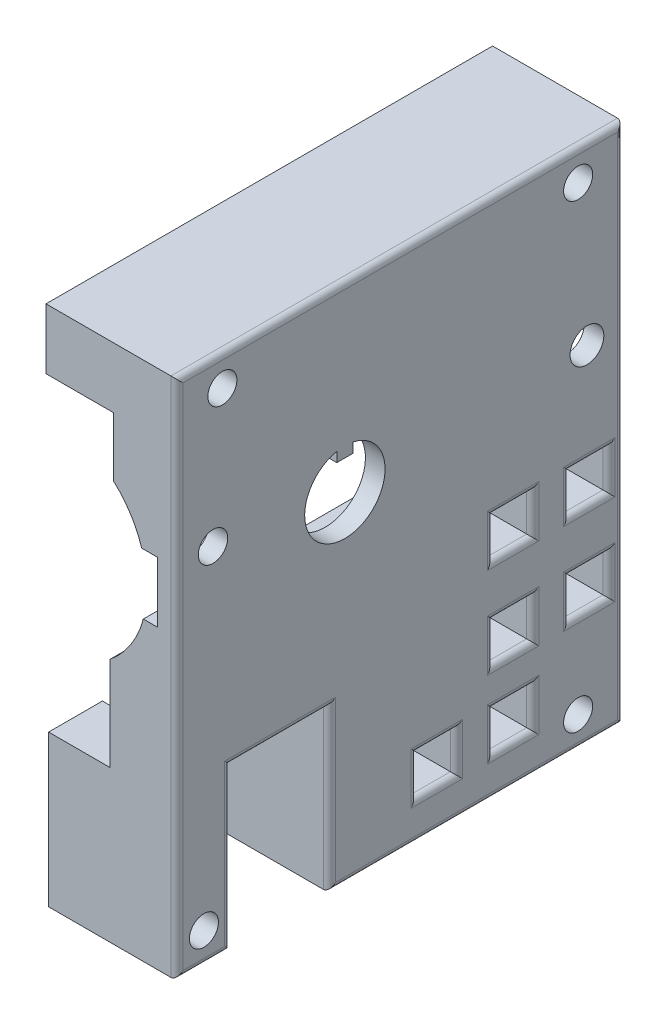
from build123d import *

# Parameters (mm, degrees)
PROFILEEXTRUDE_DEPTH = 73.76
HOSEWINDOW_W         = 16.29
HOSEWINDOW_H         = 26.5
HOSEWINDOWCUT_DEPTH  = 22.63
CAGESCREWS_R         = 2.4
CAGESCREWSCUT_DEPTH  = 22.63
AXLEHOLECUT_DEPTH    = 22.63
SETSCREWS_R          = 2.426338021
SETSCREWS_R_2        = 2.788762315
SETSCREWSCUT_DEPTH   = 22.63
SKETCH1_W            = 6.5
SKETCH1_H            = 6.5
CUT_EXTRUDE1_DEPTH   = 22.63
FILLET1_R            = 1


with BuildPart() as part:
    # Profile → ProfileExtrude (new body)
    with BuildSketch(Plane.XY):
        with BuildLine():
            Line((-6.01073477, -58.62791746), (-6.01073477, -33.62791746))
            Line((-6.01073477, -33.62791746), (4.13926523, -33.62791746))
            Line((4.13926523, -33.62791746), (4.13926523, -18.13791746))
            ThreePointArc((4.13926523, -18.13791746), (7.563334043, -14.326029686), (9.63126523, -9.63791746))
            Line((9.63126523, -9.63791746), (11.94926523, -9.63791746))
            Line((11.94926523, -9.63791746), (11.94926523, 0.36208254))
            Line((11.94926523, 0.36208254), (9.35926523, 0.36208254))
            ThreePointArc((9.35926523, 0.36208254), (7.525939238, 4.313848402), (4.70926523, 7.63708254))
            Line((4.70926523, 7.63708254), (4.70926523, 17.41208254))
            Line((4.70926523, 17.41208254), (-6.44073477, 17.41208254))
            Line((-6.44073477, 17.41208254), (-6.44073477, 27.41208254))
            Line((-6.44073477, 27.41208254), (15.18926523, 27.41208254))
            Line((15.18926523, 27.41208254), (15.18926523, -58.62791746))
            Line((15.18926523, -58.62791746), (-6.01073477, -58.62791746))
        make_face()
    extrude(amount=PROFILEEXTRUDE_DEPTH)

    # HoseWindow → HoseWindowCut (cut, through all)
    with BuildSketch(Plane(origin=(15.18926523, 0, 0), x_dir=(0, 0, -1), z_dir=(1, 0, 0))):
        with Locations((-56.725, -45.37791746)):
            Rectangle(HOSEWINDOW_W, HOSEWINDOW_H)
    extrude(amount=-HOSEWINDOWCUT_DEPTH, mode=Mode.SUBTRACT)

    # CageScrews → CageScrewsCut (cut, through all)
    with BuildSketch(Plane(origin=(15.18926523, 0, 0), x_dir=(0, 0, -1), z_dir=(1, 0, 0))):
        with Locations((-66.26, 22.41208254)):
            Circle(CAGESCREWS_R)
        with Locations((-7.5, 22.41208254)):
            Circle(CAGESCREWS_R)
        with Locations((-7.5, -53.62791746)):
            Circle(CAGESCREWS_R)
        with Locations((-69.31, -53.62791746)):
            Circle(CAGESCREWS_R)
    extrude(amount=-CAGESCREWSCUT_DEPTH, mode=Mode.SUBTRACT)

    # AxleHole → AxleHoleCut (cut, through all)
    with BuildSketch(Plane(origin=(15.18926523, 0, 0), x_dir=(0, 0, -1), z_dir=(1, 0, 0))):
        with BuildLine():
            Line((-44.699, 2.307293484), (-47.361, 2.307293484))
            Line((-47.361, 2.307293484), (-47.361, 3.926293484))
            ThreePointArc((-47.361, 3.926293484), (-46.03, -9.21691746), (-44.699, 3.926293484))
            Line((-44.699, 3.926293484), (-44.699, 2.307293484))
        make_face()
    extrude(amount=-AXLEHOLECUT_DEPTH, mode=Mode.SUBTRACT)

    # SetScrews → SetScrewsCut (cut, through all)
    with BuildSketch(Plane(origin=(15.18926523, 0, 0), x_dir=(0, 0, -1), z_dir=(1, 0, 0))):
        with Locations((-67.80722939, 0.544946624)):
            Circle(SETSCREWS_R)
        with Locations((-6.04299884, -1.55824191)):
            Circle(SETSCREWS_R_2)
    extrude(amount=-SETSCREWSCUT_DEPTH, mode=Mode.SUBTRACT)

    # Sketch1 → Cut-Extrude1 (cut, through all)
    with BuildSketch(Plane(origin=(15.18926523, 0, 0), x_dir=(0, 0, -1), z_dir=(1, 0, 0))):
        with Locations((-18.25, -49.02791746)):
            Rectangle(SKETCH1_W, SKETCH1_H)
        with Locations((-30.85, -49.02791746)):
            Rectangle(SKETCH1_W, SKETCH1_H)
        with Locations((-5.65, -36.32791746)):
            Rectangle(SKETCH1_W, SKETCH1_H)
        with Locations((-18.25, -36.32791746)):
            Rectangle(SKETCH1_W, SKETCH1_H)
        with Locations((-5.65, -21.32791746)):
            Rectangle(SKETCH1_W, SKETCH1_H)
        with Locations((-18.25, -21.32791746)):
            Rectangle(SKETCH1_W, SKETCH1_H)
    extrude(amount=-CUT_EXTRUDE1_DEPTH, mode=Mode.SUBTRACT)

    # Fillet1
    fillet1_edges = [part.edges().sort_by_distance(p)[0] for p in [
        (15.18926523, -45.77791746, 18.25),
        (15.18926523, -49.02791746, 21.5),
        (15.18926523, -52.27791746, 18.25),
        (15.18926523, -49.02791746, 15),
        (15.18926523, -49.02791746, 34.1),
        (15.18926523, -52.27791746, 30.85),
        (15.18926523, -49.02791746, 27.6),
        (15.18926523, -45.77791746, 30.85),
        (15.18926523, -36.32791746, 8.9),
        (15.18926523, -39.57791746, 5.65),
        (15.18926523, -36.32791746, 2.4),
        (15.18926523, -33.07791746, 5.65),
        (15.18926523, -15.60791746, 0),
        (15.18926523, -36.32791746, 21.5),
        (15.18926523, -39.57791746, 18.25),
        (15.18926523, -36.32791746, 15),
        (15.18926523, -33.07791746, 18.25),
        (15.18926523, -21.32791746, 8.9),
        (15.18926523, -24.57791746, 5.65),
        (15.18926523, -21.32791746, 2.4),
        (15.18926523, -18.07791746, 5.65),
        (15.18926523, -58.62791746, 69.315),
        (15.18926523, -21.32791746, 21.5),
        (15.18926523, -24.57791746, 18.25),
        (15.18926523, -21.32791746, 15),
        (15.18926523, -18.07791746, 18.25),
        (15.18926523, 27.41208254, 36.88),
        (15.18926523, -58.62791746, 24.29),
        (15.18926523, -15.60791746, 73.76),
        (15.18926523, -45.37791746, 64.87),
        (15.18926523, -45.37791746, 48.58),
        (15.18926523, -32.12791746, 56.725),
    ]]
    fillet(fillet1_edges, radius=FILLET1_R)


solid = part.part
